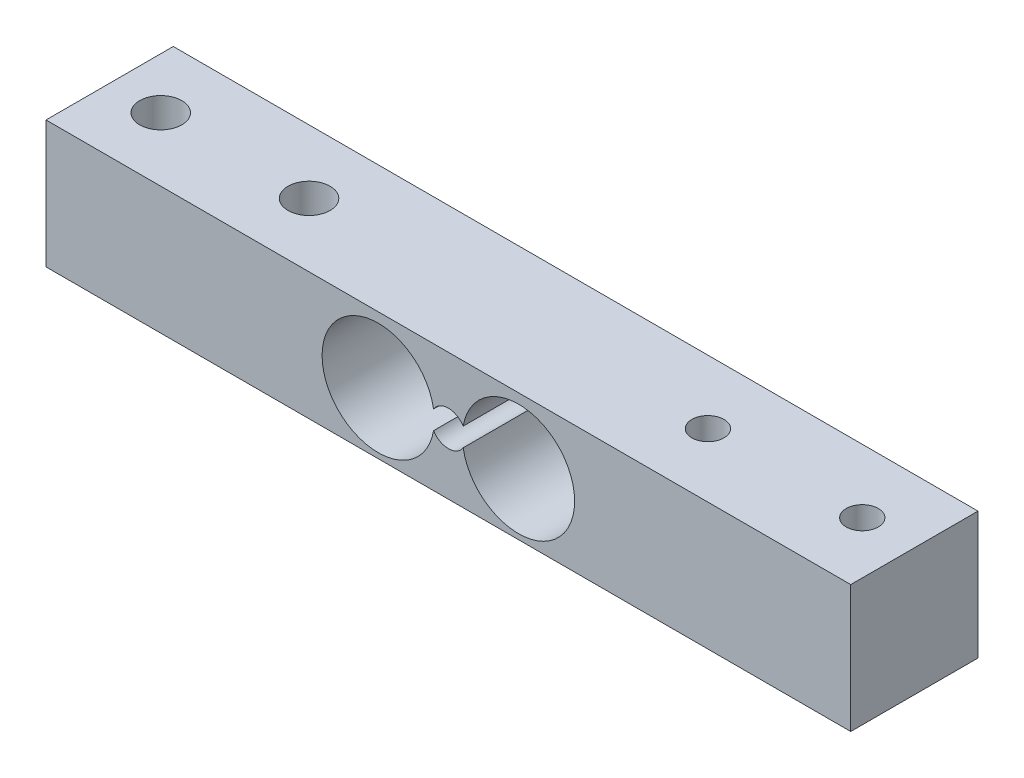
from build123d import *

# Parameters (mm, degrees)
ESQUISSE1_W             = 80.3
ESQUISSE1_H             = 12.7
BOSS_EXTRU_1_DEPTH      = 12.7
ESQUISSE2_R             = 2.1
ESQUISSE2_R_2           = 1.6
ENL_V_MAT_EXTRU_1_DEPTH = 12.7
ENL_V_MAT_EXTRU_2_DEPTH = 12.7


with BuildPart() as part:
    # Esquisse1 → Boss.-Extru.1 (new body)
    with BuildSketch(Plane(origin=(0, 0, 0), x_dir=(1, 0, 0), z_dir=(0, 1, 0))):
        with Locations((40.15, -6.35)):
            Rectangle(ESQUISSE1_W, ESQUISSE1_H)
    extrude(amount=BOSS_EXTRU_1_DEPTH)

    # Esquisse2 → Enlèv. mat.-Extru.1 (cut)
    with BuildSketch(Plane(origin=(0, 12.7, 0), x_dir=(1, 0, 0), z_dir=(0, 1, 0))):
        with Locations((5.1, -6.35)):
            Circle(ESQUISSE2_R)
        with Locations((19.9, -6.35)):
            Circle(ESQUISSE2_R)
        with Locations((59.7, -6.35)):
            Circle(ESQUISSE2_R_2)
        with Locations((75.1, -6.35)):
            Circle(ESQUISSE2_R_2)
    extrude(amount=-ENL_V_MAT_EXTRU_1_DEPTH, mode=Mode.SUBTRACT)

    # Esquisse3 → Enlèv. mat.-Extru.2 (cut)
    with BuildSketch(Plane.XY.offset(12.7)):
        with BuildLine():
            ThreePointArc((38.67125, 7.057070345), (27.55, 6.121229313), (38.67125, 5.185388281))
            ThreePointArc((38.67125, 5.185388281), (40.15, 4.371229313), (41.62875, 5.185388281))
            ThreePointArc((41.62875, 5.185388281), (52.75, 6.121229313), (41.62875, 7.057070345))
            ThreePointArc((41.62875, 7.057070345), (40.15, 7.871229313), (38.67125, 7.057070345))
        make_face()
    extrude(amount=-ENL_V_MAT_EXTRU_2_DEPTH, mode=Mode.SUBTRACT)


solid = part.part
